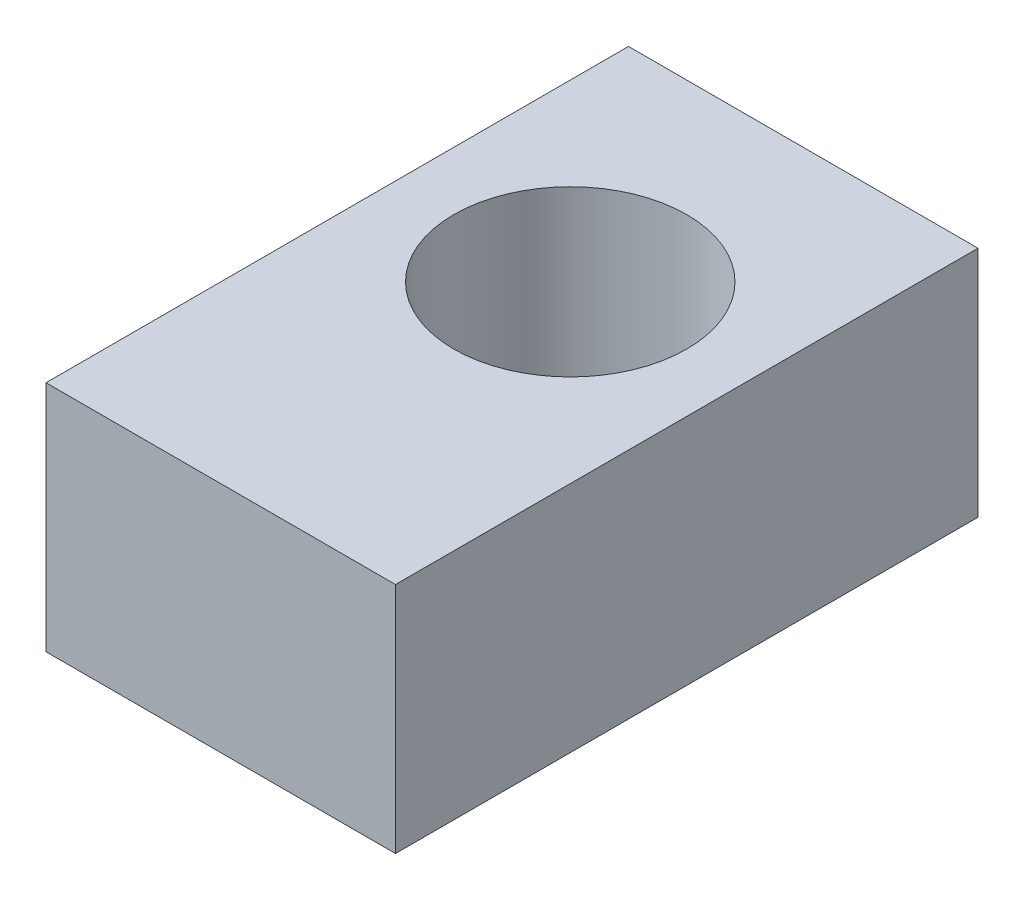
from build123d import *

# Parameters (mm, degrees)
SKETCH1_W           = 30
SKETCH1_H           = 50
SKETCH1_R           = 10
BOSS_EXTRUDE1_DEPTH = 10


with BuildPart() as part:
    # Sketch1 → Boss-Extrude1 (new body, symmetric)
    with BuildSketch(Plane(origin=(0, 0, 0), x_dir=(1, 0, 0), z_dir=(0, 1, 0))):
        with Locations((15, 25)):
            Rectangle(SKETCH1_W, SKETCH1_H)
        with Locations((15, 30)):
            Circle(SKETCH1_R, mode=Mode.SUBTRACT)
    extrude(amount=BOSS_EXTRUDE1_DEPTH, both=True)


solid = part.part
